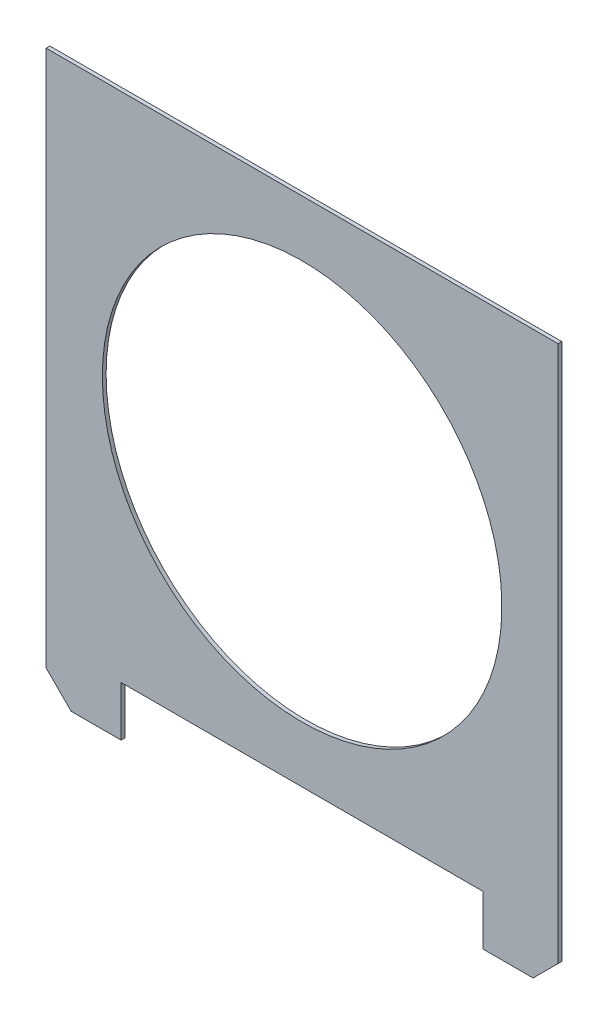
from build123d import *

# Parameters (mm, degrees)
ESQUISSE1_W             = 41
ESQUISSE1_H             = 41
BOSS_EXTRU_1_DEPTH      = 0.3
ESQUISSE2_W             = 6
ESQUISSE2_H             = 4
BOSS_EXTRU_2_DEPTH      = 0.3
ESQUISSE3_R             = 12.5
ENL_V_MAT_EXTRU_1_DEPTH = 1.3
ESQUISSE4_R             = 16
ENL_V_MAT_EXTRU_2_DEPTH = 1.3
CHANFREIN1_SIZE         = 2
CHANFREIN2_SIZE         = 2
ESQUISSE6_W             = 6
ESQUISSE6_H             = 4
ENL_V_MAT_EXTRU_4_DEPTH = 1.3


with BuildPart() as part:
    # Esquisse1 → Boss.-Extru.1 (new body)
    with BuildSketch(Plane.XY):
        Rectangle(ESQUISSE1_W, ESQUISSE1_H)
    extrude(amount=BOSS_EXTRU_1_DEPTH)

    # Esquisse2 → Boss.-Extru.2 (add)
    with BuildSketch(Plane(origin=(0, 0, 0), x_dir=(-1, 0, 0), z_dir=(0, 0, -1))):
        with Locations((17.5, 22.5)):
            Rectangle(ESQUISSE2_W, ESQUISSE2_H)
        with Locations((-17.5, -22.5)):
            Rectangle(ESQUISSE2_W, ESQUISSE2_H)
        with Locations((17.5, -22.5)):
            Rectangle(ESQUISSE2_W, ESQUISSE2_H)
    extrude(amount=-BOSS_EXTRU_2_DEPTH)

    # Esquisse3 → Enlèv. mat.-Extru.1 (cut, through all)
    with BuildSketch(Plane(origin=(0, 0, 0), x_dir=(-1, 0, 0), z_dir=(0, 0, -1))):
        Circle(ESQUISSE3_R)
    extrude(amount=-ENL_V_MAT_EXTRU_1_DEPTH, mode=Mode.SUBTRACT)

    # Esquisse4 → Enlèv. mat.-Extru.2 (cut, through all)
    with BuildSketch(Plane(origin=(0, 0, 0), x_dir=(-1, 0, 0), z_dir=(0, 0, -1))):
        Circle(ESQUISSE4_R)
    extrude(amount=-ENL_V_MAT_EXTRU_2_DEPTH, mode=Mode.SUBTRACT)

    # Chanfrein1
    chanfrein1_edges = [part.edges().sort_by_distance(p)[0] for p in [
        (-20.5, -24.5, 0.15),
    ]]
    chamfer(chanfrein1_edges, length=CHANFREIN1_SIZE)

    # Chanfrein2
    chanfrein2_edges = [part.edges().sort_by_distance(p)[0] for p in [
        (20.5, -24.5, 0.15),
    ]]
    chamfer(chanfrein2_edges, length=CHANFREIN2_SIZE)

    # Esquisse6 → Enlèv. mat.-Extru.4 (cut, through all)
    with BuildSketch(Plane(origin=(0, 0, 0), x_dir=(-1, 0, 0), z_dir=(0, 0, -1))):
        with Locations((17.5, 22.5)):
            Rectangle(ESQUISSE6_W, ESQUISSE6_H)
    extrude(amount=-ENL_V_MAT_EXTRU_4_DEPTH, mode=Mode.SUBTRACT)


solid = part.part
